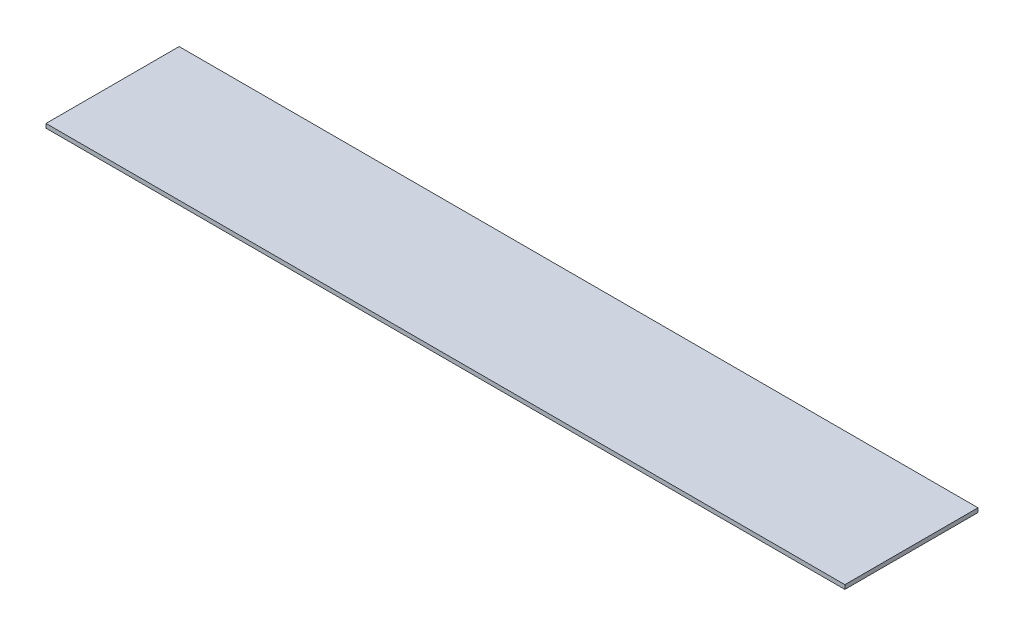
from build123d import *

# Parameters (mm, degrees)
SKETCH1_W           = 304.8
SKETCH1_H           = 50.8
BOSS_EXTRUDE1_DEPTH = 1.5875


with BuildPart() as part:
    # Sketch1 → Boss-Extrude1 (new body)
    with BuildSketch(Plane(origin=(0, 0, 0), x_dir=(1, 0, 0), z_dir=(0, 1, 0))):
        with Locations((152.4, 25.4)):
            Rectangle(SKETCH1_W, SKETCH1_H)
    extrude(amount=BOSS_EXTRUDE1_DEPTH)


solid = part.part
